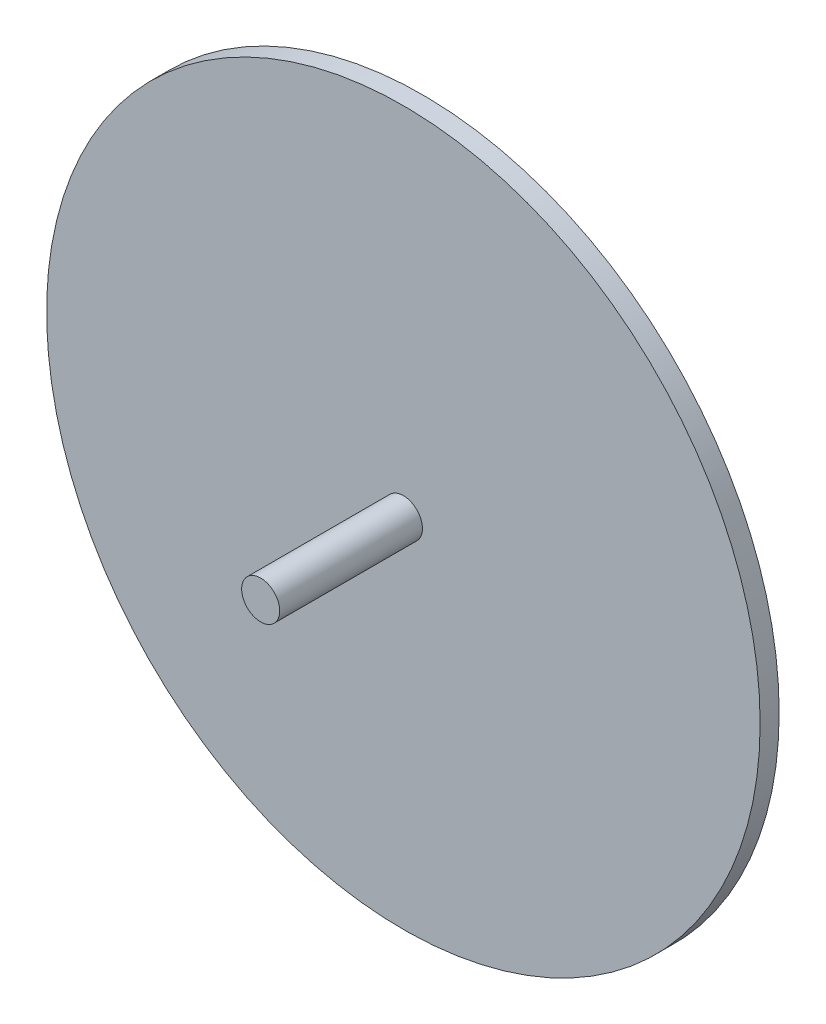
from build123d import *

# Parameters (mm, degrees)
SKETCH2_R           = 75
BOSS_EXTRUDE1_DEPTH = 4
SKETCH3_R           = 4
BOSS_EXTRUDE2_DEPTH = 30


with BuildPart() as part:
    # Sketch2 → Boss-Extrude1 (new body)
    with BuildSketch(Plane.XY):
        Circle(SKETCH2_R)
    extrude(amount=BOSS_EXTRUDE1_DEPTH)

    # Sketch3 → Boss-Extrude2 (add)
    with BuildSketch(Plane.XY.offset(4)):
        Circle(SKETCH3_R)
    extrude(amount=BOSS_EXTRUDE2_DEPTH)


solid = part.part
